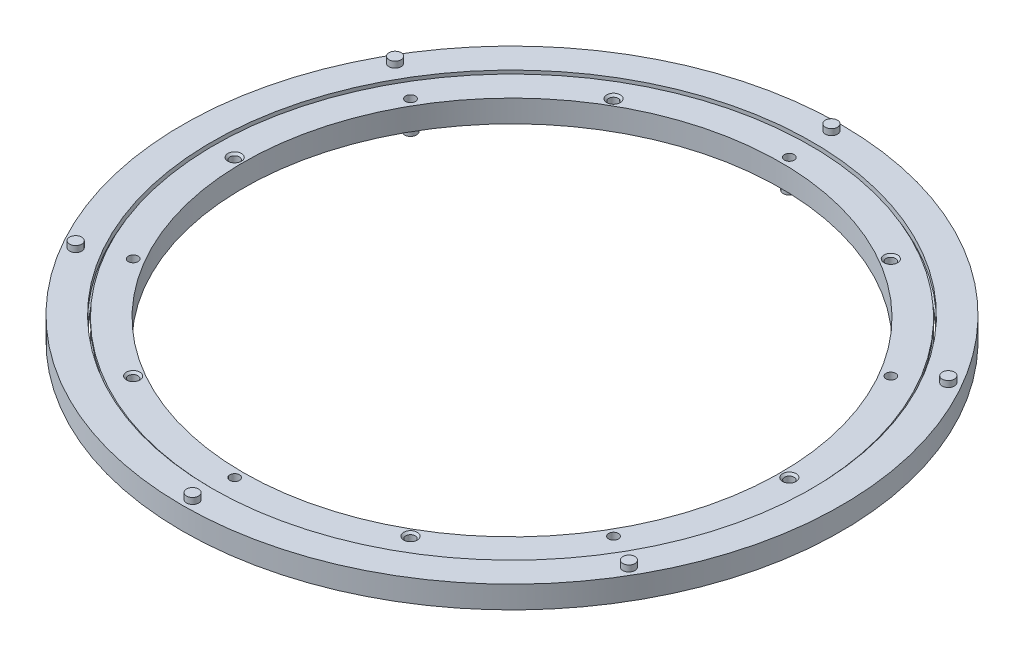
from build123d import *

# Parameters (mm, degrees)
SKETCH6_R                    = 2.35
CUT_EXTRUDE2_DEPTH           = 7
CHAMFER1_SIZE                = 1.000000032
CIRPATTERN1_COUNT            = 6
CHAMFER1_OF_CIRPATTERN1_SIZE = 1.000000032
SKETCH7_R                    = 2.4
CUT_EXTRUDE3_DEPTH           = 6.5
CIRPATTERN2_COUNT            = 6
SKETCH8_R                    = 2.4
CUT_EXTRUDE4_DEPTH           = 12
CIRPATTERN3_COUNT            = 6
CIRPATTERN4_COUNT            = 6
CIRPATTERN5_COUNT            = 6


with BuildPart() as part:
    # Sketch4 → Revolve1 (revolve)
    with BuildSketch(Plane(origin=(0, 0, 0), x_dir=(0, 0, -1), z_dir=(1, 0, 0))):
        with BuildLine():
            Line((147, 5), (147, 3.211308145))
            ThreePointArc((147, 3.211308145), (144.25, 0), (147, -3.211308145))
            Line((147, -3.211308145), (147, -6))
            Line((147, -6), (132.5, -6))
            Line((132.5, -6), (132.5, 5))
            Line((132.5, 5), (147, 5))
        make_face()
        with BuildLine():
            Line((162.5, -5), (162.5, 6))
            Line((162.5, 6), (148, 6))
            Line((148, 6), (148, 3.211308145))
            ThreePointArc((148, 3.211308145), (150.75, 0), (148, -3.211308145))
            Line((148, -3.211308145), (148, -5))
            Line((148, -5), (162.5, -5))
        make_face()
    revolve(axis=Axis((0, 6, 0), (0, -1, 0)))

    # Sketch6 → Cut-Extrude2 (cut, symmetric)
    with BuildSketch(Plane(origin=(0, 0, 0), x_dir=(1, 0, 0), z_dir=(0, 1, 0))):
        with Locations((68.375, 118.428973968)):
            Circle(SKETCH6_R)
    cut_extrude2 = extrude(amount=CUT_EXTRUDE2_DEPTH, both=True, mode=Mode.SUBTRACT)

    # Chamfer1
    chamfer1_edges = [part.edges().sort_by_distance(p)[0] for p in [
        (66.025, 5, -118.428973968),
    ]]
    chamfer(chamfer1_edges, length=CHAMFER1_SIZE)

    # CirPattern1: Cut-Extrude2 ×6 about axis
    cirpattern1_axis = Axis((0, 6, 0), (0, -1, 0))
    for i in range(1, CIRPATTERN1_COUNT):
        add(cut_extrude2.rotate(cirpattern1_axis, i * 360 / CIRPATTERN1_COUNT), mode=Mode.SUBTRACT)

    # Chamfer1 of CirPattern1
    chamfer1_of_cirpattern1_edges = [part.edges().sort_by_distance(p)[0] for p in [
        (135.575, 5, -2.035159699),
        (69.55, 5, 116.393814269),
        (-66.025, 5, 118.428973968),
        (-135.575, 5, 2.035159699),
        (-69.55, 5, -116.393814269),
    ]]
    chamfer(chamfer1_of_cirpattern1_edges, length=CHAMFER1_OF_CIRPATTERN1_SIZE)

    # Sketch7 → Cut-Extrude3 (cut)
    with BuildSketch(Plane(origin=(0, 6, 0), x_dir=(1, 0, 0), z_dir=(0, 1, 0))):
        with Locations((0, 157.5)):
            Circle(SKETCH7_R)
    cut_extrude3 = extrude(amount=-CUT_EXTRUDE3_DEPTH, mode=Mode.SUBTRACT)

    # CirPattern2: Cut-Extrude3 ×6 about axis
    cirpattern2_axis = Axis((0, 0, 0), (0, 1, 0))
    for i in range(1, CIRPATTERN2_COUNT):
        add(cut_extrude3.rotate(cirpattern2_axis, i * 360 / CIRPATTERN2_COUNT), mode=Mode.SUBTRACT)

    # Sketch8 → Cut-Extrude4 (cut, through all)
    with BuildSketch(Plane(origin=(0, 5, 0), x_dir=(1, 0, 0), z_dir=(0, 1, 0))):
        with Locations((0, 136.75)):
            Circle(SKETCH8_R)
    cut_extrude4 = extrude(amount=-CUT_EXTRUDE4_DEPTH, mode=Mode.SUBTRACT)

    # CirPattern3: Cut-Extrude4 ×6 about axis
    cirpattern3_axis = Axis((0, 0, 0), (0, 1, 0))
    for i in range(1, CIRPATTERN3_COUNT):
        add(cut_extrude4.rotate(cirpattern3_axis, i * 360 / CIRPATTERN3_COUNT), mode=Mode.SUBTRACT)


with BuildPart() as body_2:
    # Sketch9 → Revolve2 (revolve)
    with BuildSketch(Plane(origin=(0, 0, 0), x_dir=(0, 0, -1), z_dir=(1, 0, 0))):
        Polygon((157.5, -0.5), (157.5, 9), (160.5, 9), (160.5, 6), (159.9, 6), (159.9, -0.5), align=None)
    revolve(axis=Axis((0, -5, -157.5), (0, 1, 0)))


with BuildPart() as cirpattern4_1:
    # CirPattern4: pattern copy
    add(body_2.part.rotate(Axis((0, 0, 0), (0, 1, 0)), 1 * 360 / CIRPATTERN4_COUNT))


with BuildPart() as cirpattern4_2:
    # CirPattern4: pattern copy
    add(body_2.part.rotate(Axis((0, 0, 0), (0, 1, 0)), 2 * 360 / CIRPATTERN4_COUNT))


with BuildPart() as cirpattern4_3:
    # CirPattern4: pattern copy
    add(body_2.part.rotate(Axis((0, 0, 0), (0, 1, 0)), 3 * 360 / CIRPATTERN4_COUNT))


with BuildPart() as cirpattern4_4:
    # CirPattern4: pattern copy
    add(body_2.part.rotate(Axis((0, 0, 0), (0, 1, 0)), 4 * 360 / CIRPATTERN4_COUNT))


with BuildPart() as cirpattern4_5:
    # CirPattern4: pattern copy
    add(body_2.part.rotate(Axis((0, 0, 0), (0, 1, 0)), 5 * 360 / CIRPATTERN4_COUNT))


with BuildPart() as body_8:
    # Sketch10 → Revolve3 (revolve)
    with BuildSketch(Plane(origin=(0, 0, 0), x_dir=(0, 0, -1), z_dir=(1, 0, 0))):
        Polygon((134.35, -6), (133.75, -6), (133.75, -9), (136.75, -9), (136.75, 0.5), (134.35, 0.5), align=None)
    revolve(axis=Axis((0, 5, -136.75), (0, -1, 0)))


with BuildPart() as cirpattern5_1:
    # CirPattern5: pattern copy
    add(body_8.part.rotate(Axis((0, 0, 0), (0, 1, 0)), 1 * 360 / CIRPATTERN5_COUNT))


with BuildPart() as cirpattern5_2:
    # CirPattern5: pattern copy
    add(body_8.part.rotate(Axis((0, 0, 0), (0, 1, 0)), 2 * 360 / CIRPATTERN5_COUNT))


with BuildPart() as cirpattern5_3:
    # CirPattern5: pattern copy
    add(body_8.part.rotate(Axis((0, 0, 0), (0, 1, 0)), 3 * 360 / CIRPATTERN5_COUNT))


with BuildPart() as cirpattern5_4:
    # CirPattern5: pattern copy
    add(body_8.part.rotate(Axis((0, 0, 0), (0, 1, 0)), 4 * 360 / CIRPATTERN5_COUNT))


with BuildPart() as cirpattern5_5:
    # CirPattern5: pattern copy
    add(body_8.part.rotate(Axis((0, 0, 0), (0, 1, 0)), 5 * 360 / CIRPATTERN5_COUNT))


solid = Compound([part.part, body_2.part, cirpattern4_1.part, cirpattern4_2.part, cirpattern4_3.part, cirpattern4_4.part, cirpattern4_5.part, body_8.part, cirpattern5_1.part, cirpattern5_2.part, cirpattern5_3.part, cirpattern5_4.part, cirpattern5_5.part])
